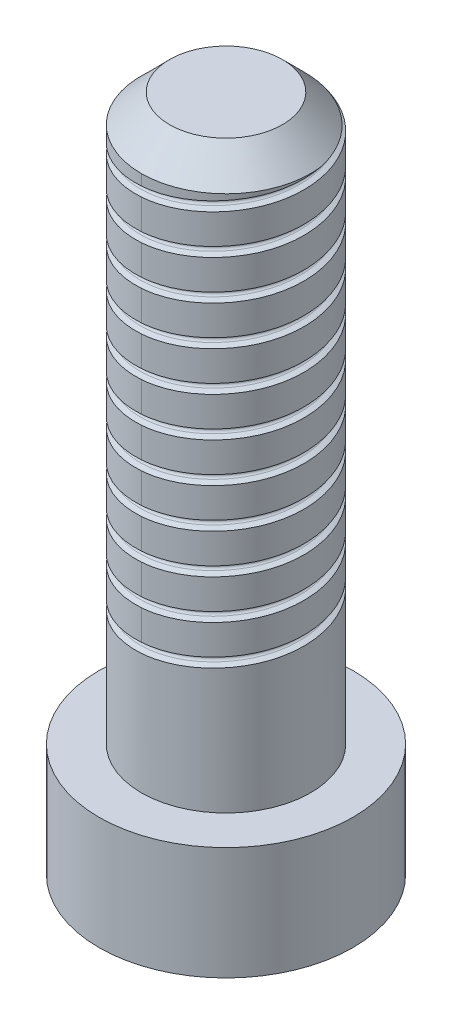
from build123d import *

# Parameters (mm, degrees)
SKETCH1_R              = 2.25
BOSS_EXTRUDE1_DEPTH    = 12
SKETCH2_OUTSIDE_W      = 9.216
SKETCH2_OUTSIDE_H      = 9.216
SKETCH2_OUTSIDE_R      = 1.5
CUT_EXTRUDE1_DEPTH     = 10
CHAMFER1_SIZE          = 0.5
CUT_SWEEP1_PITCH       = 0.7
CUT_SWEEP1_HEIGHT      = 8
CUT_SWEEP1_RADIUS      = 1.5
CUT_SWEEP1_START_ANGLE = 180
CUT_EXTRUDE2_DEPTH     = 1.5


with BuildPart() as part:
    # Sketch1 → Boss-Extrude1 (new body)
    with BuildSketch(Plane(origin=(0, 0, 0), x_dir=(1, 0, 0), z_dir=(0, 1, 0))):
        Circle(SKETCH1_R)
    extrude(amount=BOSS_EXTRUDE1_DEPTH)

    # Sketch2 outside → Cut-Extrude1 (cut)
    with BuildSketch(Plane(origin=(0, 12, 0), x_dir=(1, 0, 0), z_dir=(0, 1, 0))):
        Rectangle(SKETCH2_OUTSIDE_W, SKETCH2_OUTSIDE_H)
        Circle(SKETCH2_OUTSIDE_R, mode=Mode.SUBTRACT)
    extrude(amount=-CUT_EXTRUDE1_DEPTH, mode=Mode.SUBTRACT)

    # Chamfer1
    chamfer1_edges = [part.edges().sort_by_distance(p)[0] for p in [
        (-1.5, 12, 0),
    ]]
    chamfer(chamfer1_edges, length=CHAMFER1_SIZE)

    # Cut-Sweep1: sweep along a helix
    with BuildLine() as cut_sweep1_path:
        add(Helix(CUT_SWEEP1_PITCH, CUT_SWEEP1_HEIGHT, CUT_SWEEP1_RADIUS, center=(0, 12, 0), direction=(0, -1, 0), mode=Mode.PRIVATE).rotate(Axis((0, 12, 0), (0, -1, 0)), CUT_SWEEP1_START_ANGLE))
    # Sketch7 → Cut-Sweep1 (sweep, cut)
    with BuildSketch(Plane(origin=(0, 12, 1.5), x_dir=(0, 0, 1), z_dir=(-0.997253171, -0.074068293, 0))):
        with BuildLine():
            Line((-0.081023547, -0.030253267), (0.549038106, 0.274742329))
            Line((0.549038106, 0.274742329), (0.549038106, -0.425257671))
            Line((0.549038106, -0.425257671), (-0.081023547, -0.120262075))
            ThreePointArc((-0.081023547, -0.120262075), (-0.109238147, -0.075257671), (-0.081023547, -0.030253267))
        make_face()
    sweep(path=cut_sweep1_path.line, is_frenet=True, mode=Mode.SUBTRACT)

    # Sketch8 → Cut-Extrude2 (cut)
    with BuildSketch(Plane.XZ):
        Polygon((1.154700538, 0), (0.577350269, 1), (-0.577350269, 1), (-1.154700538, 0), (-0.577350269, -1), (0.577350269, -1), align=None)
    extrude(amount=-CUT_EXTRUDE2_DEPTH, mode=Mode.SUBTRACT)


solid = part.part
